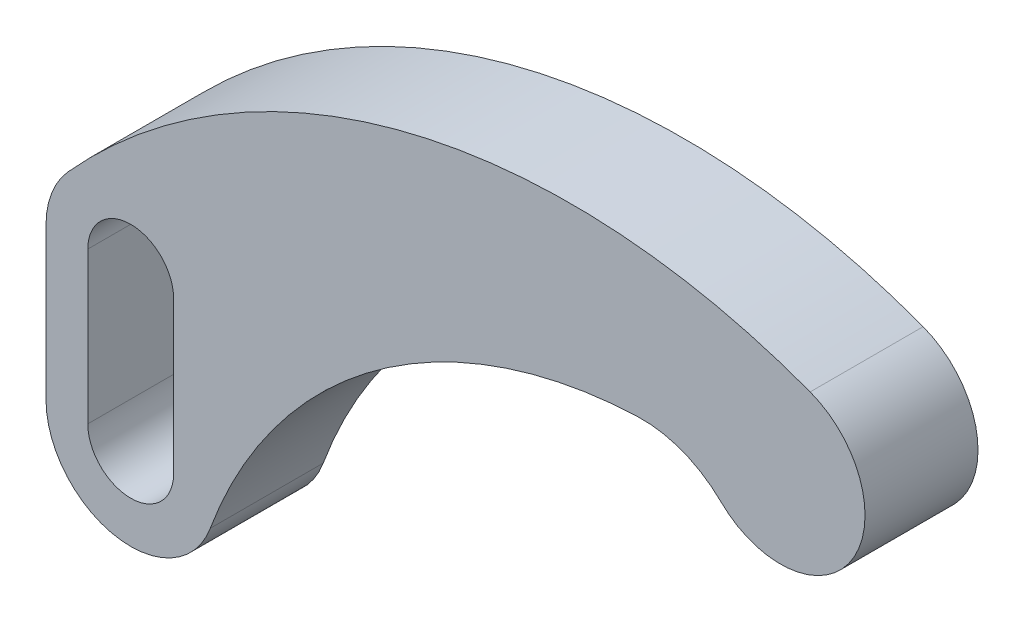
from build123d import *

# Parameters (mm, degrees)
BOSS_EXTRUDE1_DEPTH = 25.4


with BuildPart() as part:
    # Sketch1 → Boss-Extrude1 (new body)
    with BuildSketch(Plane.XY):
        with BuildLine():
            Line((-165.1, -35.56), (-165.1, -69.596))
            ThreePointArc((-165.1, -69.596), (-149.387691218, -88.351327705), (-128.169572983, -76.168125204))
            ThreePointArc((-128.169572983, -76.168125204), (-90.731121166, -26.656656194), (-32.067687872, -6.368116766))
            ThreePointArc((-32.067687872, -6.368116766), (-21.95402191, -8.057064985), (-13.332222743, -13.607142857))
            ThreePointArc((-13.332222743, -13.607142857), (16.063246399, -10.240830783), (6.709524974, 17.829323448))
            ThreePointArc((6.709524974, 17.829323448), (-83.019510627, 23.268882931), (-160.20476074, -22.810676552))
            ThreePointArc((-160.20476074, -22.810676552), (-163.834131861, -28.731592137), (-165.1, -35.56))
        make_face()
        with BuildLine():
            Line((-136.398, -35.56), (-136.398, -69.596))
            ThreePointArc((-136.398, -69.596), (-146.05, -79.248), (-155.702, -69.596))
            Line((-155.702, -69.596), (-155.702, -35.56))
            ThreePointArc((-155.702, -35.56), (-146.05, -25.908), (-136.398, -35.56))
        make_face(mode=Mode.SUBTRACT)
    extrude(amount=BOSS_EXTRUDE1_DEPTH)


solid = part.part
